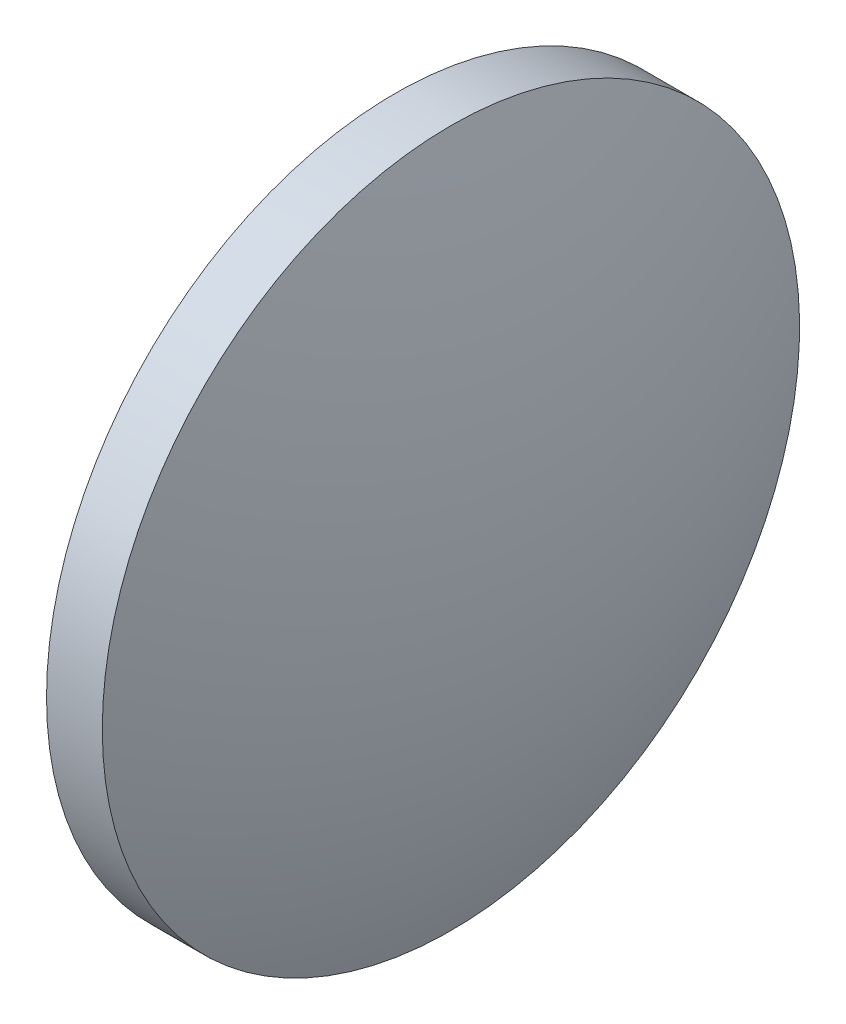
from build123d import *


with BuildPart() as part:
    # 草图1 → 旋转1 (revolve)
    with BuildSketch(Plane.XY):
        with BuildLine():
            Line((364.969960555, 381.227799172), (364.969960555, 388.727799172))
            Line((364.969960555, 388.727799172), (366.169960555, 388.727799172))
            ThreePointArc((366.169960555, 388.727799172), (367.216963656, 385.042573084), (367.569960555, 381.227799172))
            Line((367.569960555, 381.227799172), (364.969960555, 381.227799172))
        make_face()
    revolve(axis=Axis((362.129148425, 381.227799172, 0), (1, 0, 0)))


solid = part.part
